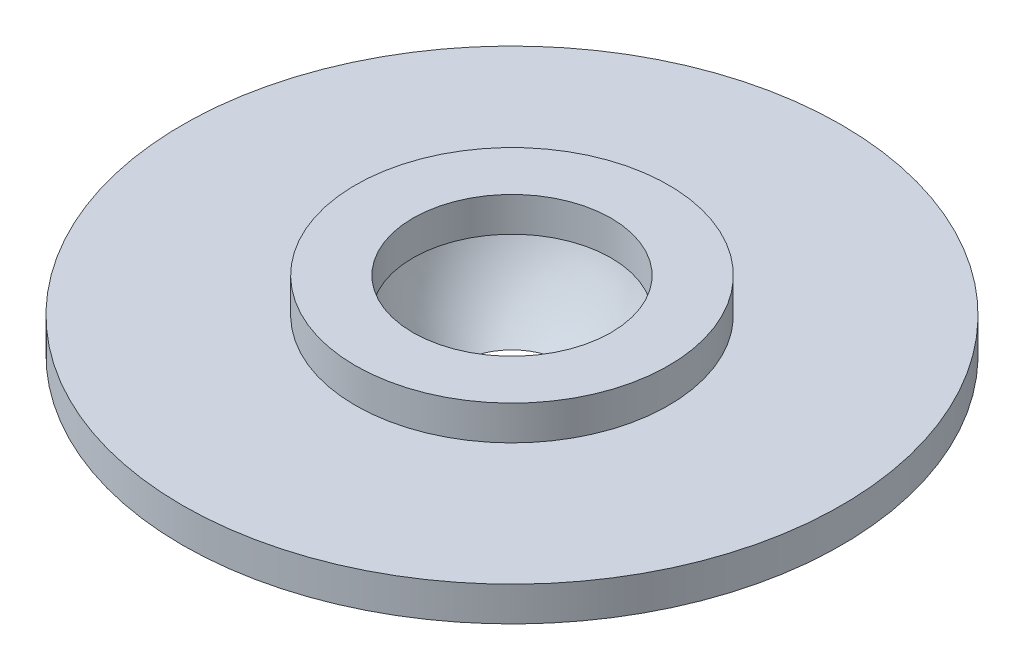
from build123d import *


with BuildPart() as part:
    # Эскиз1 → Повернуть1 (revolve)
    with BuildSketch(Plane.XY):
        with BuildLine():
            Line((12.029960322, 8.361249018), (19, 8.361249018))
            Line((19, 8.361249018), (19, 4.180624509))
            Line((19, 4.180624509), (40, 4.180624509))
            Line((40, 4.180624509), (40, 0))
            Line((40, 0), (19, 0))
            Line((19, 0), (19, -4))
            Line((19, -4), (6.398915065, -4))
            ThreePointArc((6.398915065, -4), (9.695038318, -0.240504038), (12.029960322, 4.180624509))
            Line((12.029960322, 4.180624509), (12.029960322, 8.361249018))
        make_face()
    revolve(axis=Axis((0, 35.151373423, 0), (0, -1, 0)))


solid = part.part
